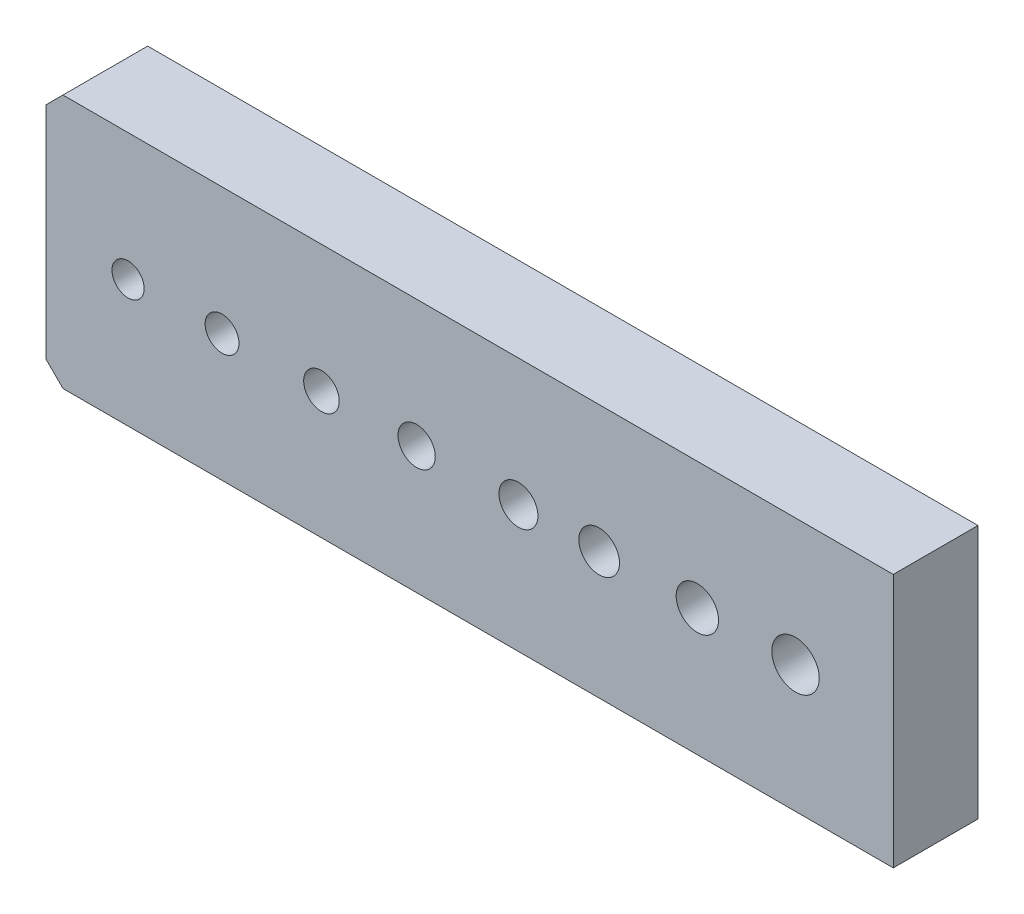
from build123d import *

# Parameters (mm, degrees)
SKETCH1_W           = 50
SKETCH1_H           = 15
BOSS_EXTRUDE1_DEPTH = 5
SKETCH2_R           = 0.95
SKETCH2_R_2         = 1
SKETCH2_R_3         = 1.05
SKETCH2_R_4         = 1.1
SKETCH2_R_5         = 1.15
SKETCH2_R_6         = 1.2
SKETCH2_R_7         = 1.25
SKETCH2_R_8         = 1.4
CUT_EXTRUDE1_DEPTH  = 6
CHAMFER1_SIZE       = 1


with BuildPart() as part:
    # Sketch1 → Boss-Extrude1 (new body)
    with BuildSketch(Plane.XY):
        Rectangle(SKETCH1_W, SKETCH1_H)
    extrude(amount=BOSS_EXTRUDE1_DEPTH)

    # Sketch2 → Cut-Extrude1 (cut, through all)
    with BuildSketch(Plane.XY.offset(5)):
        with Locations((-20.156657813, 0)):
            Circle(SKETCH2_R)
        with Locations((-14.61091069, 0)):
            Circle(SKETCH2_R_2)
        with Locations((-8.745216617, 0)):
            Circle(SKETCH2_R_3)
        with Locations((-3.128370172, 0)):
            Circle(SKETCH2_R_4)
        with Locations((2.879522545, 0)):
            Circle(SKETCH2_R_5)
        with Locations((7.643177125, 0)):
            Circle(SKETCH2_R_6)
        with Locations((13.437771876, 0)):
            Circle(SKETCH2_R_7)
        with Locations((19.232366626, 0)):
            Circle(SKETCH2_R_8)
    extrude(amount=-CUT_EXTRUDE1_DEPTH, mode=Mode.SUBTRACT)

    # Chamfer1
    chamfer1_edges = [part.edges().sort_by_distance(p)[0] for p in [
        (-25, -7.5, 2.5),
        (-25, 7.5, 2.5),
    ]]
    chamfer(chamfer1_edges, length=CHAMFER1_SIZE)


solid = part.part
